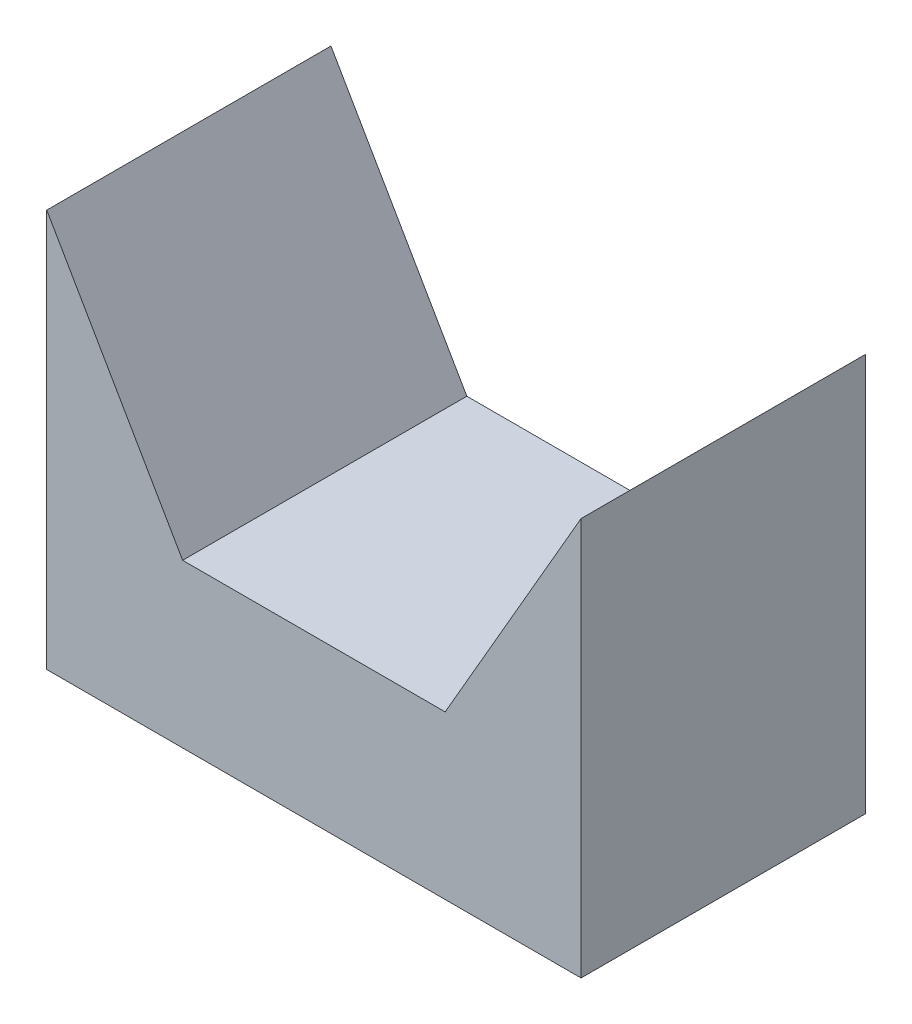
from build123d import *

# Parameters (mm, degrees)
Y_KSEKLIK_EKSTR_ZYON1_DEPTH = 5


with BuildPart() as part:
    # Çizim1 → Yükseklik-Ekstrüzyon1 (new body)
    with BuildSketch(Plane.XY.offset(4.115610561)):
        Polygon((-4.7, 0.140638796), (-4.7, -6.859361204), (4.7, -6.859361204), (4.7, 0.140638796), (2.309401077, -4), (-2.309401077, -4), align=None)
    extrude(amount=Y_KSEKLIK_EKSTR_ZYON1_DEPTH)


solid = part.part
